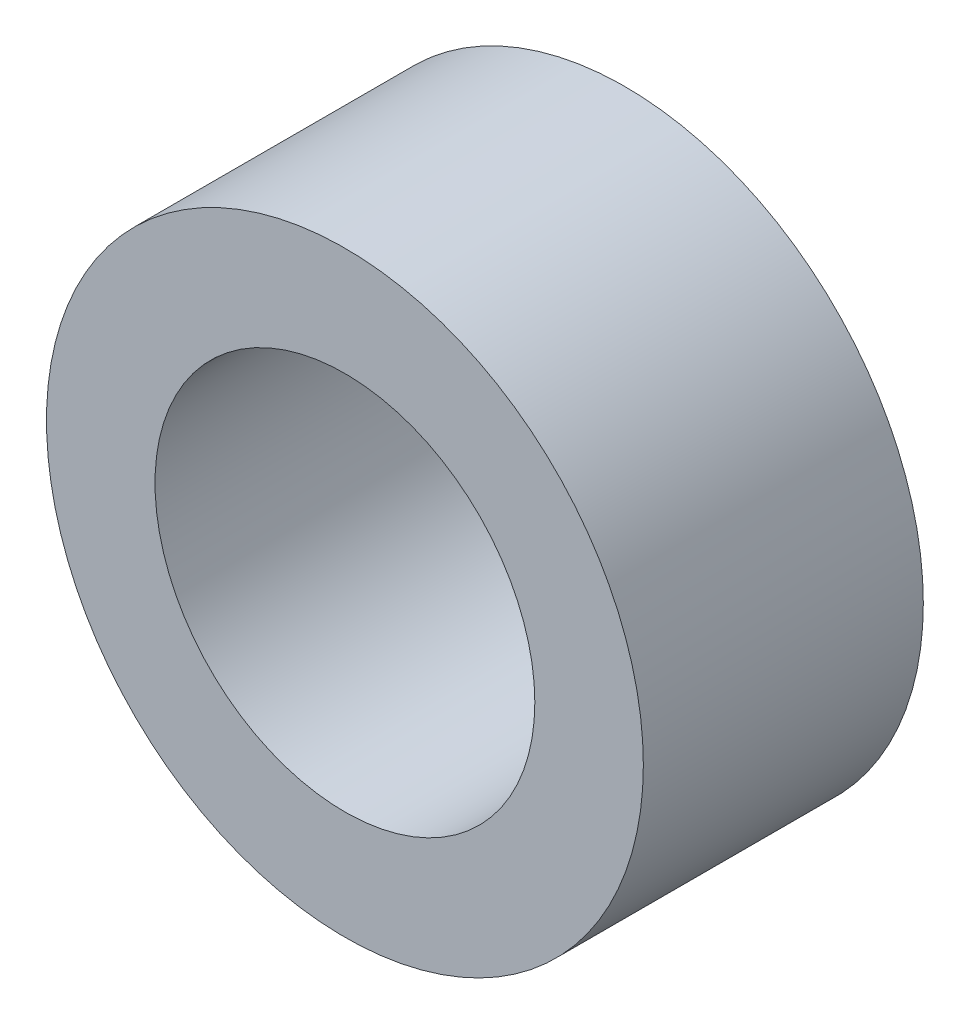
from build123d import *

# Parameters (mm, degrees)
SKETCH1_R           = 13.75
SKETCH1_R_2         = 8.75
BOSS_EXTRUDE1_DEPTH = 12.9


with BuildPart() as part:
    # Sketch1 → Boss-Extrude1 (new body)
    with BuildSketch(Plane.XY):
        Circle(SKETCH1_R)
        Circle(SKETCH1_R_2, mode=Mode.SUBTRACT)
    extrude(amount=BOSS_EXTRUDE1_DEPTH)


solid = part.part
